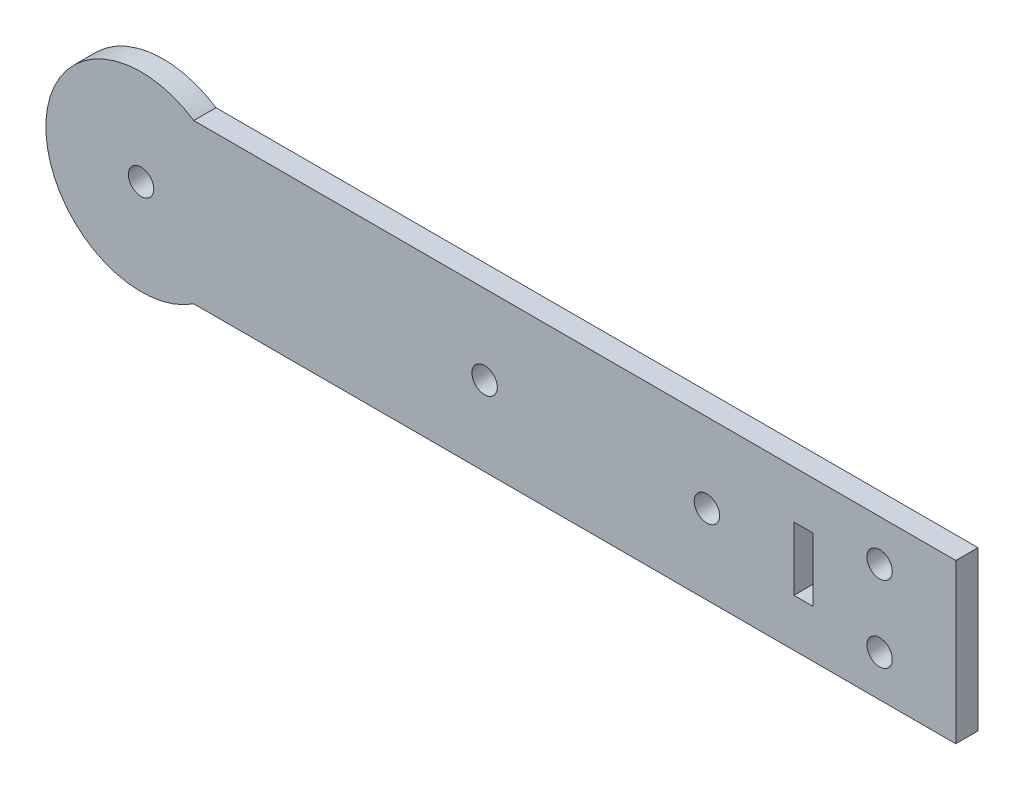
from build123d import *

# Parameters (mm, degrees)
CROQUIS1_R              = 2
CROQUIS1_W              = 3
CROQUIS1_H              = 10
SALIENTE_EXTRUIR2_DEPTH = 3.5


with BuildPart() as part:
    # Croquis1 → Saliente-Extruir2 (new body)
    with BuildSketch(Plane.XY):
        with BuildLine():
            Line((34.902189702, 12.5), (34.902189702, -12.5))
            Line((34.902189702, -12.5), (-85.097810298, -12.5))
            ThreePointArc((-85.097810298, -12.5), (-108.389372273, 0), (-85.097810298, 12.5))
            Line((-85.097810298, 12.5), (34.902189702, 12.5))
        make_face()
        with Locations((-93.389372273, 0)):
            Circle(CROQUIS1_R, mode=Mode.SUBTRACT)
        with Locations((22.902189702, 6)):
            Circle(CROQUIS1_R, mode=Mode.SUBTRACT)
        with Locations((22.902189702, -6)):
            Circle(CROQUIS1_R, mode=Mode.SUBTRACT)
        with Locations((-39.291561976, 0)):
            Circle(CROQUIS1_R, mode=Mode.SUBTRACT)
        with Locations((-4.291561976, 0)):
            Circle(CROQUIS1_R, mode=Mode.SUBTRACT)
        with Locations((10.902189702, 0)):
            Rectangle(CROQUIS1_W, CROQUIS1_H, mode=Mode.SUBTRACT)
    extrude(amount=SALIENTE_EXTRUIR2_DEPTH)


solid = part.part
